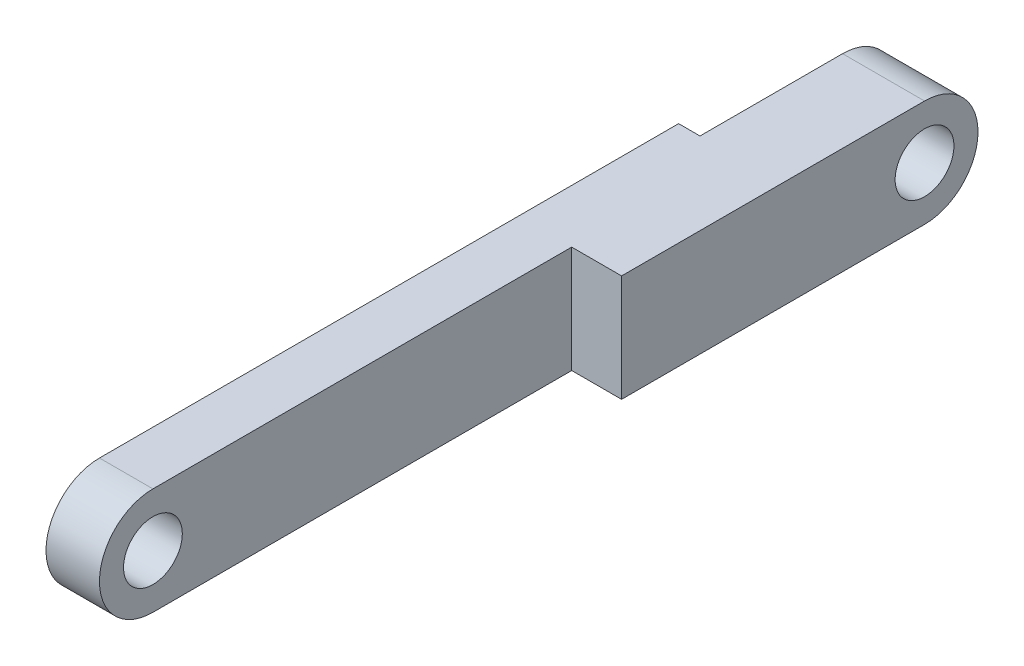
from build123d import *

# Parameters (mm, degrees)
SKETCH1_R           = 1.65
BOSS_EXTRUDE1_DEPTH = 3
SKETCH3_W           = 11
SKETCH3_H           = 6
CUT_EXTRUDE2_DEPTH  = 1.2
SKETCH4_R           = 1.65
BOSS_EXTRUDE2_DEPTH = 2.8


with BuildPart() as part:
    # Sketch1 → Boss-Extrude1 (new body)
    with BuildSketch(Plane(origin=(0, 0, 0), x_dir=(0, 0, -1), z_dir=(1, 0, 0))):
        with BuildLine():
            Line((0, 3), (40.5, 3))
            ThreePointArc((40.5, 3), (43.5, 0), (40.5, -3))
            Line((40.5, -3), (0, -3))
            ThreePointArc((0, -3), (-3, 0), (0, 3))
        make_face()
        Circle(SKETCH1_R, mode=Mode.SUBTRACT)
        with Locations((40.5, 0)):
            Circle(SKETCH1_R, mode=Mode.SUBTRACT)
    extrude(amount=BOSS_EXTRUDE1_DEPTH)

    # Sketch3 → Cut-Extrude2 (cut)
    with BuildSketch(Plane.ZY):
        with Locations((-38, 0)):
            Rectangle(SKETCH3_W, SKETCH3_H)
    extrude(amount=-CUT_EXTRUDE2_DEPTH, mode=Mode.SUBTRACT)

    # Sketch4 → Boss-Extrude2 (add)
    with BuildSketch(Plane(origin=(3, 0, 0), x_dir=(0, 0, -1), z_dir=(1, 0, 0))):
        with BuildLine():
            Line((40.5, 3), (23.5, 3))
            Line((23.5, 3), (23.5, -3))
            Line((23.5, -3), (40.5, -3))
            ThreePointArc((40.5, -3), (43.5, 0), (40.5, 3))
        make_face()
        with Locations((40.5, 0)):
            Circle(SKETCH4_R, mode=Mode.SUBTRACT)
    extrude(amount=BOSS_EXTRUDE2_DEPTH)


solid = part.part
